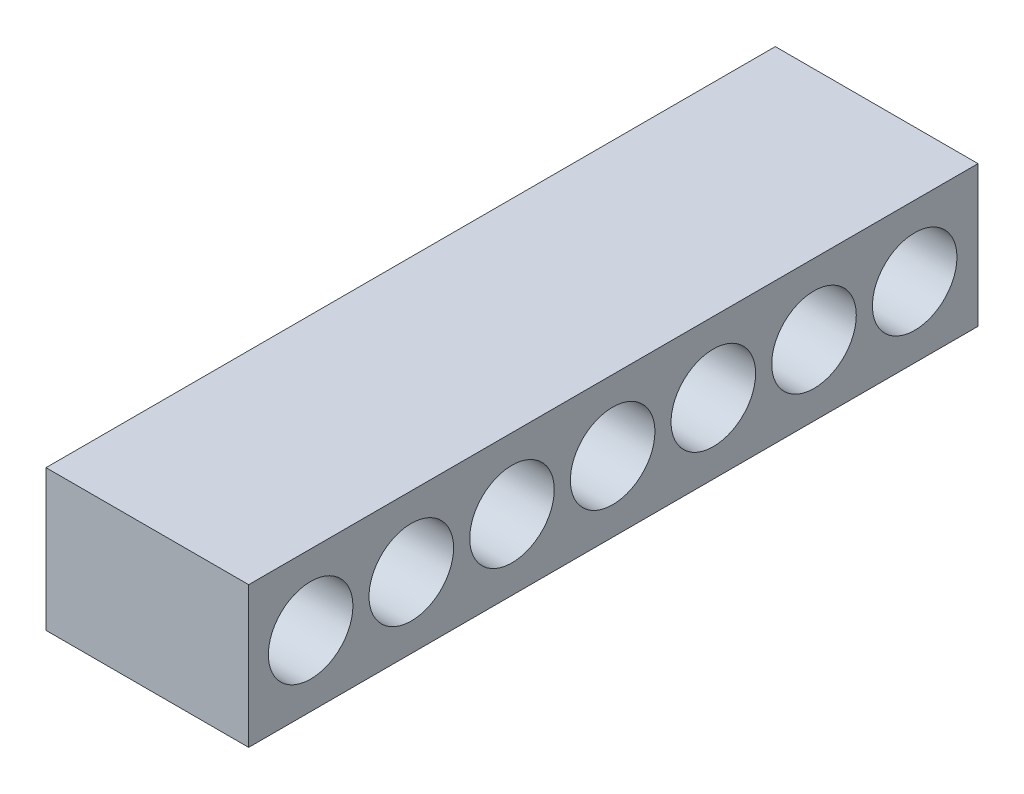
from build123d import *

# Parameters (mm, degrees)
SKETCH1_W           = 3.8354
SKETCH1_H           = 15
BOSS_EXTRUDE1_DEPTH = 2.667
SKETCH4_R           = 0.8
CUT_EXTRUDE1_DEPTH  = 1.9177
SKETCH5_R           = 0.64
CUT_EXTRUDE2_DEPTH  = 2.9177
SKETCH6_R           = 0.69
CUT_EXTRUDE3_DEPTH  = 1.27
SKETCH9_W           = 3.8354
SKETCH9_H           = 2.667
CUT_EXTRUDE5_DEPTH  = 1.2


with BuildPart() as part:
    # Sketch1 → Boss-Extrude1 (new body)
    with BuildSketch(Plane(origin=(0, 0, 0), x_dir=(1, 0, 0), z_dir=(0, 1, 0))):
        Rectangle(SKETCH1_W, SKETCH1_H)
    extrude(amount=BOSS_EXTRUDE1_DEPTH)

    # Sketch4 → Cut-Extrude1 (cut)
    with BuildSketch(Plane(origin=(1.9177, 0, 0), x_dir=(0, 0, -1), z_dir=(1, 0, 0))):
        with Locations((-6.328069737, 1.3335)):
            Circle(SKETCH4_R)
        with Locations((-4.423069737, 1.3335)):
            Circle(SKETCH4_R)
        with Locations((-2.518069737, 1.3335)):
            Circle(SKETCH4_R)
        with Locations((-0.613069737, 1.3335)):
            Circle(SKETCH4_R)
        with Locations((1.291930263, 1.3335)):
            Circle(SKETCH4_R)
        with Locations((3.196930263, 1.3335)):
            Circle(SKETCH4_R)
        with Locations((5.101930263, 1.3335)):
            Circle(SKETCH4_R)
    extrude(amount=-CUT_EXTRUDE1_DEPTH, mode=Mode.SUBTRACT)

    # Sketch5 → Cut-Extrude2 (cut, through all)
    with BuildSketch(Plane(origin=(0, 0, 0), x_dir=(0, 0, -1), z_dir=(1, 0, 0))):
        with Locations((-6.328069737, 1.3335)):
            Circle(SKETCH5_R)
        with Locations((-4.423069737, 1.3335)):
            Circle(SKETCH5_R)
        with Locations((-2.518069737, 1.3335)):
            Circle(SKETCH5_R)
        with Locations((-0.613069737, 1.3335)):
            Circle(SKETCH5_R)
        with Locations((1.291930263, 1.3335)):
            Circle(SKETCH5_R)
        with Locations((3.196930263, 1.3335)):
            Circle(SKETCH5_R)
    extrude(amount=-CUT_EXTRUDE2_DEPTH, mode=Mode.SUBTRACT)

    # Sketch6 → Cut-Extrude3 (cut)
    with BuildSketch(Plane(origin=(0, 0, 0), x_dir=(0, 0, -1), z_dir=(1, 0, 0))):
        with Locations((5.101930263, 1.3335)):
            Circle(SKETCH6_R)
    extrude(amount=-CUT_EXTRUDE3_DEPTH, mode=Mode.SUBTRACT)

    # Sketch9 → Cut-Extrude5 (cut)
    with BuildSketch(Plane(origin=(0, 0, -7.5), x_dir=(-1, 0, 0), z_dir=(0, 0, -1))):
        with Locations((0, 1.3335)):
            Rectangle(SKETCH9_W, SKETCH9_H)
    extrude(amount=-CUT_EXTRUDE5_DEPTH, mode=Mode.SUBTRACT)


solid = part.part
